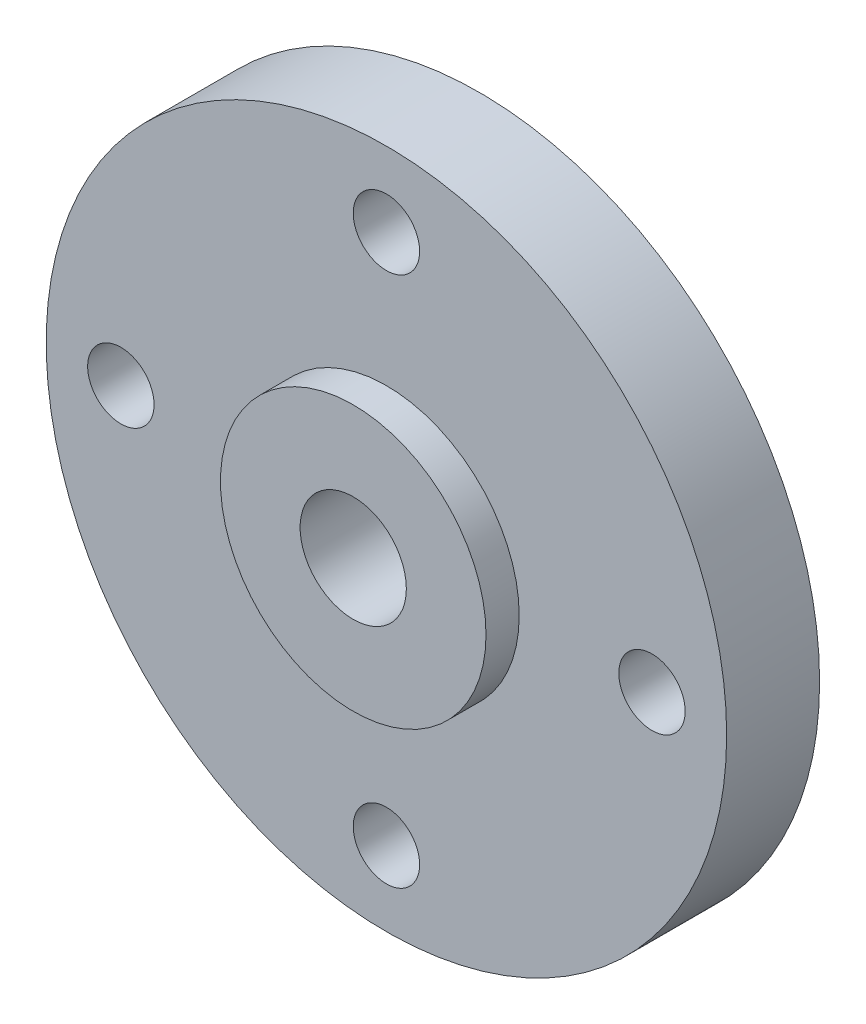
from build123d import *

# Parameters (mm, degrees)
SKETCH1_R           = 10.25
SKETCH1_R_2         = 4
BOSS_EXTRUDE1_DEPTH = 2.8
SKETCH1_3_R         = 4
SKETCH1_3_R_2       = 1.6
BOSS_EXTRUDE2_DEPTH = 3.8
SKETCH2_R           = 1
CUT_EXTRUDE1_DEPTH  = 2.8


with BuildPart() as part:
    # Sketch1 → Boss-Extrude1 (new body)
    with BuildSketch(Plane.XY):
        Circle(SKETCH1_R)
        Circle(SKETCH1_R_2, mode=Mode.SUBTRACT)
    extrude(amount=BOSS_EXTRUDE1_DEPTH)

    # Sketch1_3 → Boss-Extrude2 (add)
    with BuildSketch(Plane.XY):
        Circle(SKETCH1_3_R)
        Circle(SKETCH1_3_R_2, mode=Mode.SUBTRACT)
    extrude(amount=BOSS_EXTRUDE2_DEPTH)

    # Sketch2 → Cut-Extrude1 (cut)
    with BuildSketch(Plane.XY.offset(2.8)):
        with Locations((8, 0)):
            Circle(SKETCH2_R)
        with Locations((0, 8)):
            Circle(SKETCH2_R)
        with Locations((0, -8)):
            Circle(SKETCH2_R)
        with Locations((-8, 0)):
            Circle(SKETCH2_R)
    extrude(amount=-CUT_EXTRUDE1_DEPTH, mode=Mode.SUBTRACT)


solid = part.part
